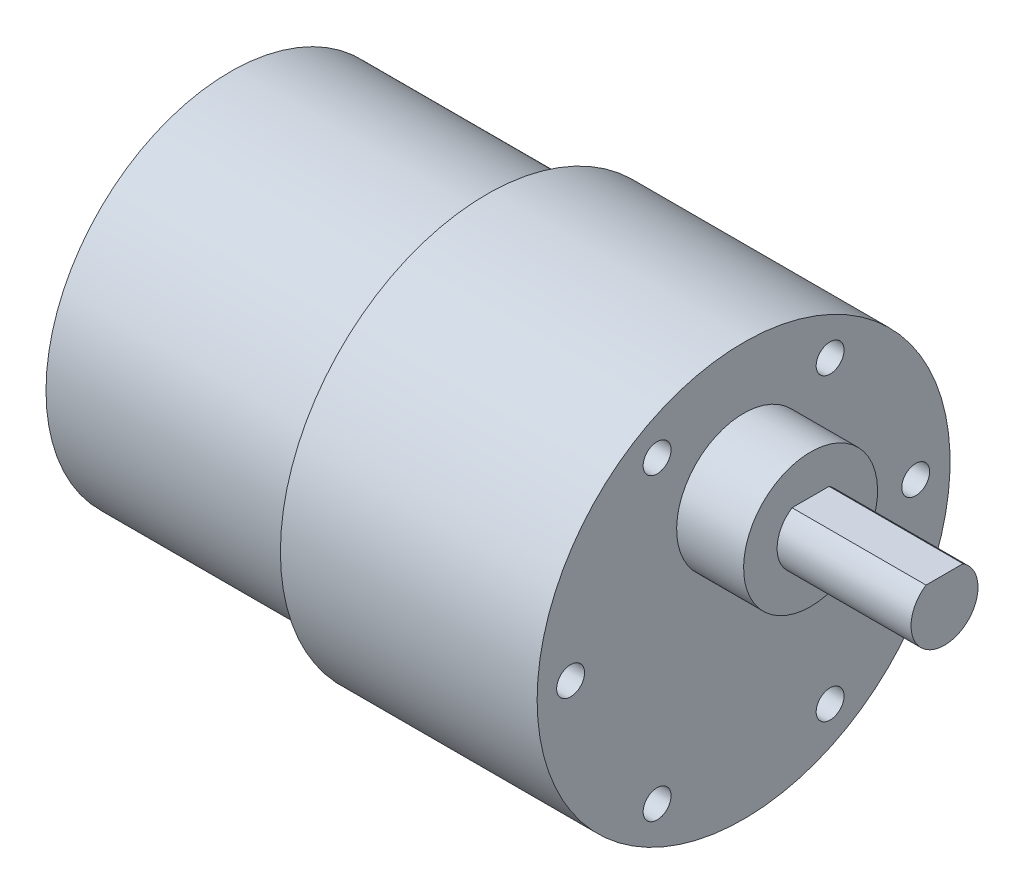
from build123d import *

# Parameters (mm, degrees)
SKETCH_3_W             = 11.653142641
SKETCH_3_H             = 0.953639491
CUT_EXTRUDE_1_DEPTH    = 12
HOLE_WIZARD_M3_1_D     = 2.5
HOLE_WIZARD_M3_1_DEPTH = 7.5
HOLE_WIZARD_M3_1_TIP   = 0.751075774


with BuildPart() as part:
    # 草图1 → 旋转1 (revolve)
    with BuildSketch(Plane.XY):
        Polygon((0, 0), (46, 0), (46, 18.5), (23, 18.5), (23, 16.5), (0, 16.5), align=None)
    revolve(axis=Axis((0, 0, 0), (1, 0, 0)))

    # 草图2 → 旋转2 (revolve)
    with BuildSketch(Plane.XY):
        Polygon((46, 7), (64, 7), (64, 4), (52, 4), (52, 1), (46, 1), align=None)
    revolve(axis=Axis((46, 7, 0), (1, 0, 0)))

    # 草图3 → 切除-拉伸1 (cut)
    with BuildSketch(Plane(origin=(64, 0, 0), x_dir=(0, 0, -1), z_dir=(1, 0, 0))):
        with Locations((-0.372215264, 9.976819746)):
            Rectangle(SKETCH_3_W, SKETCH_3_H)
    extrude(amount=-CUT_EXTRUDE_1_DEPTH, mode=Mode.SUBTRACT)

    # M3 螺纹孔1
    with Locations(Plane(origin=(46, 0, 0), x_dir=(0, 0, -1), z_dir=(1, 0, 0))):
        with Locations((-7.75, 13.423393759), (7.75, 13.423393759), (15.4165108, 0.144607536), (7.75, -13.423393759), (-7.75, -13.423393759), (-15.5, 0)):
            Hole(HOLE_WIZARD_M3_1_D / 2, depth=HOLE_WIZARD_M3_1_DEPTH)
            with Locations((0, 0, -(HOLE_WIZARD_M3_1_DEPTH + HOLE_WIZARD_M3_1_TIP / 2))):  # 118° drill point
                Cone(0, HOLE_WIZARD_M3_1_D / 2, HOLE_WIZARD_M3_1_TIP, mode=Mode.SUBTRACT)


solid = part.part
